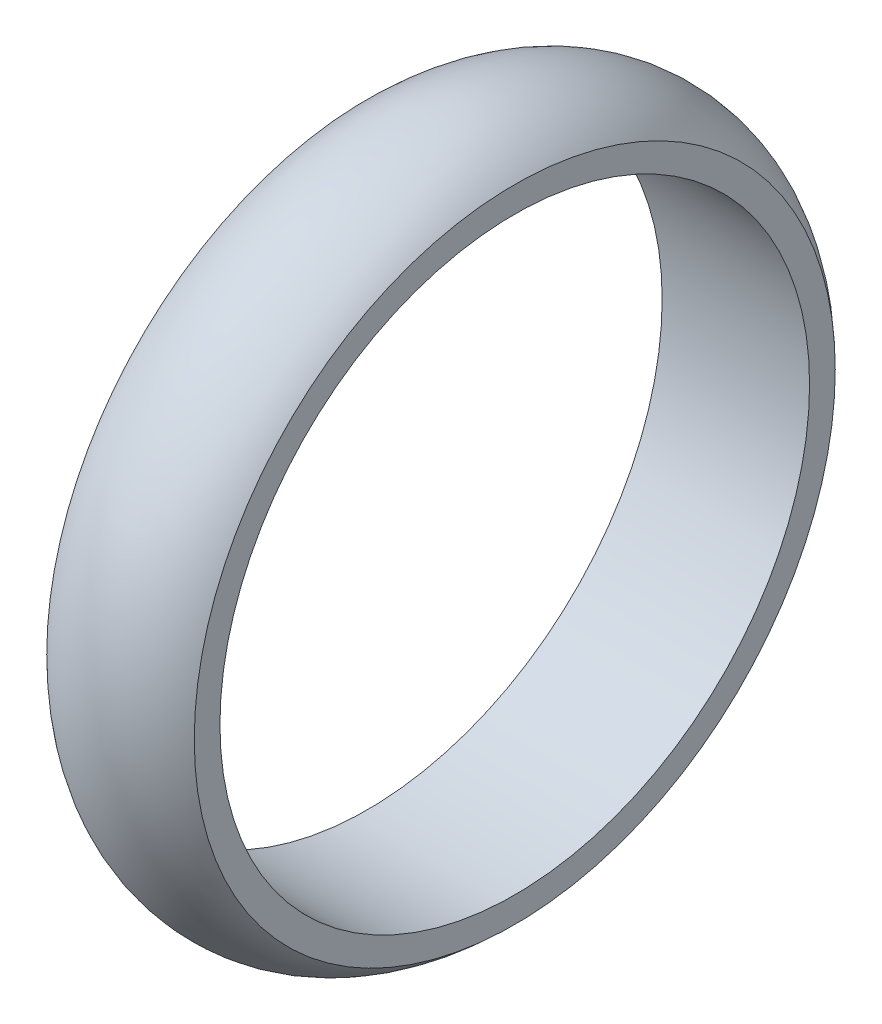
from build123d import *


with BuildPart() as part:
    # Croquis2 → Revolución1 (revolve)
    with BuildSketch(Plane.XY):
        with BuildLine():
            Line((-57.15, 228.6), (-57.15, 248.6))
            ThreePointArc((-57.15, 248.6), (0.01764896, 272.229696732), (57.15, 248.514783285))
            Line((57.15, 248.514783285), (57.15, 228.6))
            Line((57.15, 228.6), (-57.15, 228.6))
        make_face()
    revolve(axis=Axis((-19.785336719, 0, 0), (1, 0, 0)))


solid = part.part
